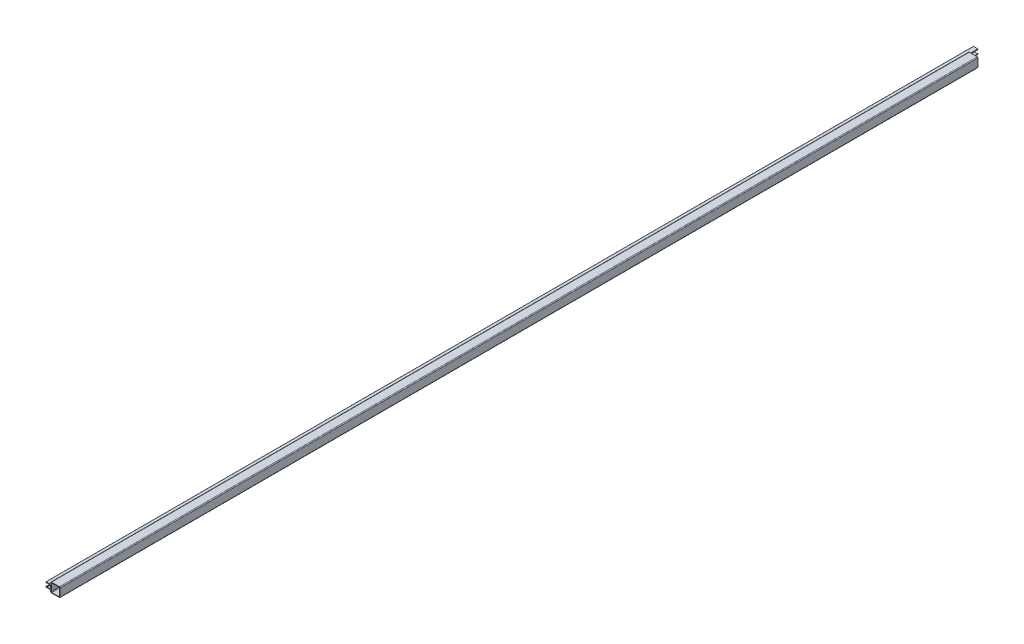
from build123d import *

# Parameters (mm, degrees)
BOSS_EXTRUDE1_DEPTH = 2500
CUT_EXTRUDE2_DEPTH  = 25.4


with BuildPart() as part:
    # Sketch1 → Boss-Extrude1 (new body)
    with BuildSketch(Plane(origin=(0, 0, -3683), x_dir=(-1, 0, 0), z_dir=(0, 0, -1))):
        with BuildLine():
            Line((25.4, -5.969), (25.4, -4.826))
            ThreePointArc((25.4, -4.826), (25.176815367, -4.287184633), (24.638, -4.064))
            Line((24.638, -4.064), (23.0632, -4.064))
            ThreePointArc((23.0632, -4.064), (22.793792316, -4.175592316), (22.6822, -4.445))
            ThreePointArc((22.6822, -4.445), (22.570607684, -4.714407684), (22.3012, -4.826))
            Line((22.3012, -4.826), (13.081, -4.826))
            ThreePointArc((13.081, -4.826), (12.811592316, -4.714407684), (12.7, -4.445))
            Line((12.7, -4.445), (12.7, 4.445))
            ThreePointArc((12.7, 4.445), (12.811592316, 4.714407684), (13.081, 4.826))
            Line((13.081, 4.826), (22.3012, 4.826))
            ThreePointArc((22.3012, 4.826), (22.570607684, 4.714407684), (22.6822, 4.445))
            ThreePointArc((22.6822, 4.445), (22.793792316, 4.175592316), (23.0632, 4.064))
            Line((23.0632, 4.064), (24.638, 4.064))
            ThreePointArc((24.638, 4.064), (25.176815367, 4.287184633), (25.4, 4.826))
            Line((25.4, 4.826), (25.4, 5.969))
            ThreePointArc((25.4, 5.969), (25.288407684, 6.238407684), (25.019, 6.35))
            Line((25.019, 6.35), (13.081, 6.35))
            ThreePointArc((13.081, 6.35), (12.811592316, 6.461592316), (12.7, 6.731))
            Line((12.7, 6.731), (12.7, 10.5918))
            ThreePointArc((12.7, 10.5918), (12.082522516, 12.082522516), (10.5918, 12.7))
            Line((10.5918, 12.7), (-10.5918, 12.7))
            ThreePointArc((-10.5918, 12.7), (-12.082522516, 12.082522516), (-12.7, 10.5918))
            Line((-12.7, 10.5918), (-12.7, -10.5918))
            ThreePointArc((-12.7, -10.5918), (-12.082522516, -12.082522516), (-10.5918, -12.7))
            Line((-10.5918, -12.7), (10.5918, -12.7))
            ThreePointArc((10.5918, -12.7), (12.082522516, -12.082522516), (12.7, -10.5918))
            Line((12.7, -10.5918), (12.7, -6.731))
            ThreePointArc((12.7, -6.731), (12.811592316, -6.461592316), (13.081, -6.35))
            Line((13.081, -6.35), (25.019, -6.35))
            ThreePointArc((25.019, -6.35), (25.288407684, -6.238407684), (25.4, -5.969))
        make_face()
        with BuildLine():
            Line((11.176, 9.652), (11.176, -9.652))
            ThreePointArc((11.176, -9.652), (10.729630735, -10.729630735), (9.652, -11.176))
            Line((9.652, -11.176), (-9.652, -11.176))
            ThreePointArc((-9.652, -11.176), (-10.729630735, -10.729630735), (-11.176, -9.652))
            Line((-11.176, -9.652), (-11.176, 9.652))
            ThreePointArc((-11.176, 9.652), (-10.729630735, 10.729630735), (-9.652, 11.176))
            Line((-9.652, 11.176), (9.652, 11.176))
            ThreePointArc((9.652, 11.176), (10.729630735, 10.729630735), (11.176, 9.652))
        make_face(mode=Mode.SUBTRACT)
    extrude(amount=-BOSS_EXTRUDE1_DEPTH)

    # Sketch2 → Cut-Extrude2 (cut)
    with BuildSketch(Plane(origin=(0, 0, -3683), x_dir=(-1, 0, 0), z_dir=(0, 0, -1))):
        with BuildLine():
            Line((12.758304506, -12.7), (12.758304506, 12.7))
            Line((12.758304506, 12.7), (10.5918, 12.7))
            Line((10.5918, 12.7), (-10.5918, 12.7))
            ThreePointArc((-10.5918, 12.7), (-12.082522516, 12.082522516), (-12.7, 10.5918))
            Line((-12.7, 10.5918), (-12.7, -12.909808873))
            Line((-12.7, -12.909808873), (-10.5918, -12.7))
            Line((-10.5918, -12.7), (12.758304506, -12.7))
        make_face()
    extrude(amount=-CUT_EXTRUDE2_DEPTH, mode=Mode.SUBTRACT)


solid = part.part
